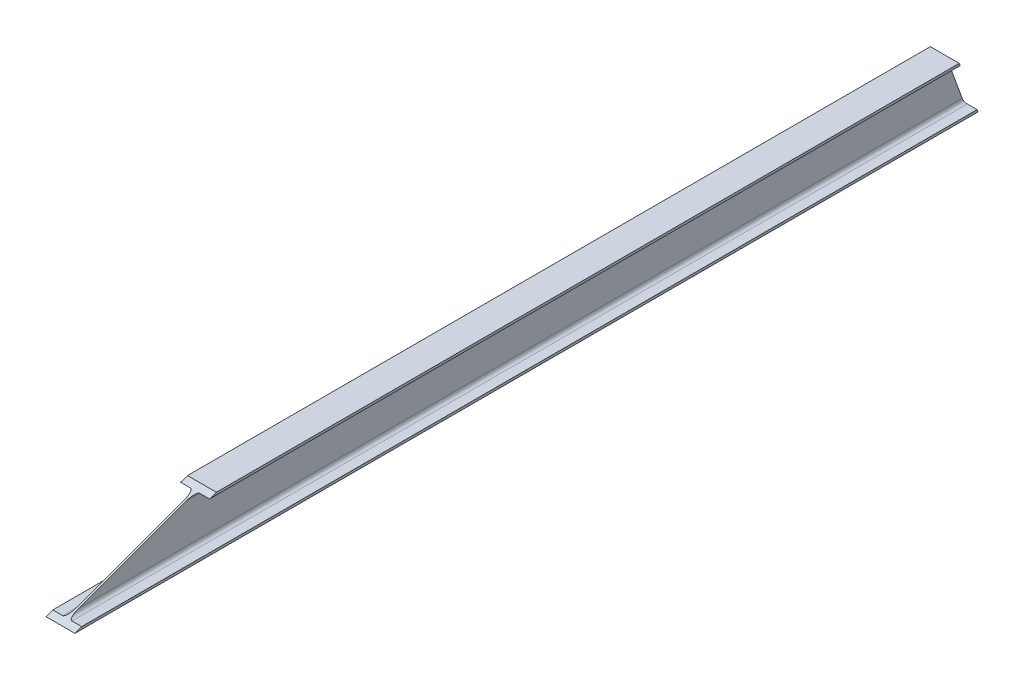
from build123d import *

# Parameters (mm, degrees)
BOSS_EXTRUDE1_DEPTH     = 1726.350547376
SKETCH2_W               = 211.702458594
SKETCH2_H               = 483.586926944
CUT_EXTRUDE1_DEPTH      = 34.517974046
SKETCH3_W               = 200.611820877
SKETCH3_H               = 857.421683483
CUT_EXTRUDE3_DEPTH      = 93.089876837
CUT_EXTRUDE3_DEPTH_BACK = 2.54


with BuildPart() as part:
    # Sketch1 → Boss-Extrude1 (new body)
    with BuildSketch(Plane.XY):
        with BuildLine():
            Line((-27.5, 49), (27.5, 49))
            Line((27.5, 49), (27.5, 44.3))
            Line((27.5, 44.3), (8.8, 44.3))
            ThreePointArc((8.8, 44.3), (3.850252532, 42.249747468), (1.8, 37.3))
            Line((1.8, 37.3), (1.8, -37.3))
            ThreePointArc((1.8, -37.3), (3.850252532, -42.249747468), (8.8, -44.3))
            Line((8.8, -44.3), (27.5, -44.3))
            Line((27.5, -44.3), (27.5, -49))
            Line((27.5, -49), (-27.5, -49))
            Line((-27.5, -49), (-27.5, -44.3))
            Line((-27.5, -44.3), (-8.8, -44.3))
            ThreePointArc((-8.8, -44.3), (-3.850252532, -42.249747468), (-1.8, -37.3))
            Line((-1.8, -37.3), (-1.8, 37.3))
            ThreePointArc((-1.8, 37.3), (-3.850252532, 42.249747468), (-8.8, 44.3))
            Line((-8.8, 44.3), (-27.5, 44.3))
            Line((-27.5, 44.3), (-27.5, 49))
        make_face()
    extrude(amount=BOSS_EXTRUDE1_DEPTH)

    # Sketch2 → Cut-Extrude1 (cut, through all)
    with BuildSketch(Plane(origin=(0, -5.731911144, 15.748296437), x_dir=(1, 0, 0), z_dir=(0, -0.342020143, 0.939692621))):
        with Locations((0, 13.030857736)):
            Rectangle(SKETCH2_W, SKETCH2_H)
    extrude(amount=-CUT_EXTRUDE1_DEPTH, mode=Mode.SUBTRACT)

    # Sketch3 → Cut-Extrude3 (cut, two sides)
    with BuildSketch(Plane(origin=(0, 511.570282058, 186.196355404), x_dir=(1, 0, 0), z_dir=(0, 0.939692621, 0.342020143))) as cut_extrude3_sk:
        with Locations((34.7211676, -1334.740482361)):
            Rectangle(SKETCH3_W, SKETCH3_H)
    extrude(amount=CUT_EXTRUDE3_DEPTH, mode=Mode.SUBTRACT)
    extrude(cut_extrude3_sk.sketch, amount=-CUT_EXTRUDE3_DEPTH_BACK, mode=Mode.SUBTRACT)


solid = part.part
